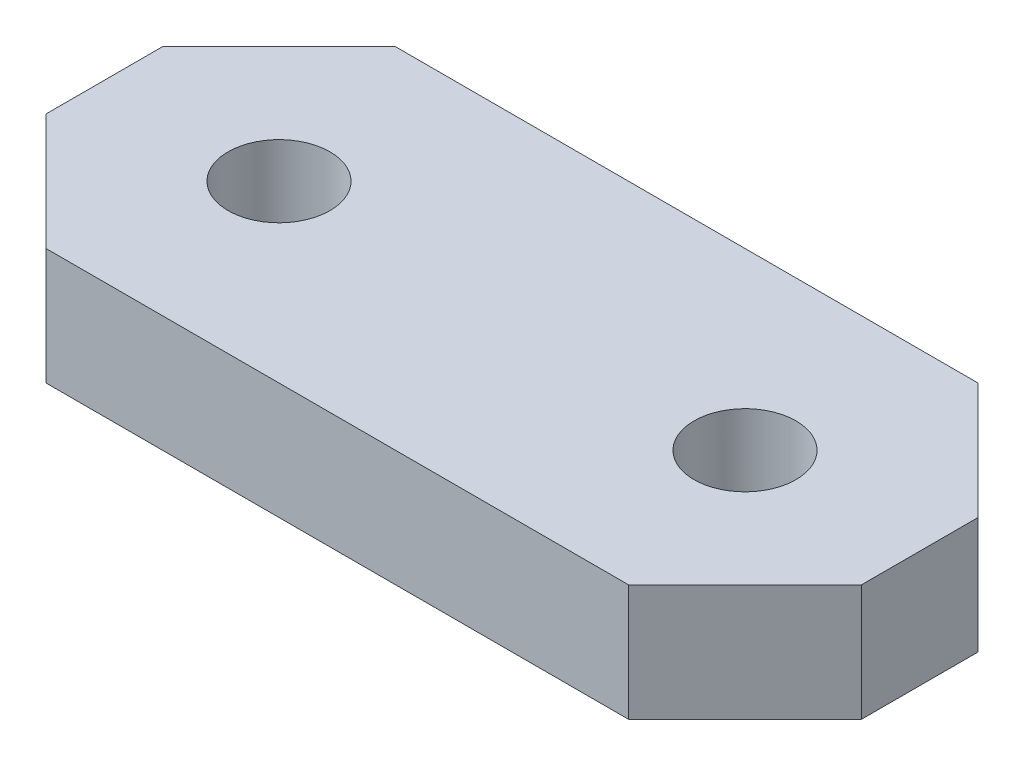
from build123d import *

# Parameters (mm, degrees)
BOSS_EXTRUDE1_DEPTH     = 12
SKETCH2_R               = 1.75
CUT_EXTRUDE1_DEPTH      = 1
CUT_EXTRUDE1_DEPTH_BACK = 5
CHAMFER1_SIZE           = 4


with BuildPart() as part:
    # Sketch1 → Boss-Extrude1 (new body)
    with BuildSketch(Plane.XY):
        Polygon((0, 0), (12, 0), (16, 0), (28, 0), (28, 4), (0, 4), align=None)
    extrude(amount=BOSS_EXTRUDE1_DEPTH)

    # Sketch2 → Cut-Extrude1 (cut, two sides)
    with BuildSketch(Plane(origin=(0, 0, 0), x_dir=(-1, 0, 0), z_dir=(0, -1, 0))) as cut_extrude1_sk:
        with Locations((-6, -6)):
            Circle(SKETCH2_R)
        with Locations((-22, -6)):
            Circle(SKETCH2_R)
    extrude(amount=CUT_EXTRUDE1_DEPTH, mode=Mode.SUBTRACT)
    extrude(cut_extrude1_sk.sketch, amount=-CUT_EXTRUDE1_DEPTH_BACK, mode=Mode.SUBTRACT)

    # Chamfer1
    chamfer1_edges = [part.edges().sort_by_distance(p)[0] for p in [
        (28, 2, 12),
        (0, 2, 12),
        (28, 2, 0),
        (0, 2, 0),
    ]]
    chamfer(chamfer1_edges, length=CHAMFER1_SIZE)


solid = part.part
